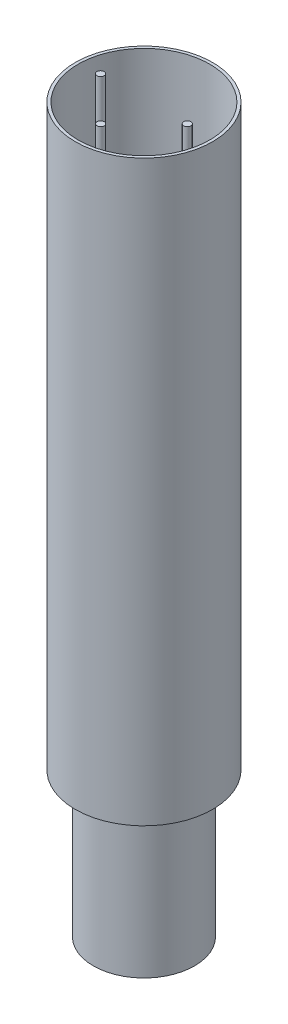
from build123d import *

# Parameters (mm, degrees)
SKETCH1_R             = 35
BOSS_EXTRUDE1_DEPTH   = 100
SKETCH2_R             = 47.5
BOSS_EXTRUDE2_DEPTH   = 400
SHELL1_T              = -2
SKETCH3_R             = 2.5
BOSS_EXTRUDE3_DEPTH   = 400
BOSS_EXTRUDE3_2_DEPTH = 400
BOSS_EXTRUDE3_3_DEPTH = 400


with BuildPart() as part:
    # Sketch1 → Boss-Extrude1 (new body)
    with BuildSketch(Plane(origin=(0, 0, 0), x_dir=(1, 0, 0), z_dir=(0, 1, 0))):
        with Locations(Location((0, 0, 0), (0, 0, 270))):
            Circle(SKETCH1_R)
    extrude(amount=BOSS_EXTRUDE1_DEPTH)

    # Sketch2 → Boss-Extrude2 (add)
    with BuildSketch(Plane(origin=(0, 100, 0), x_dir=(1, 0, 0), z_dir=(0, 1, 0))):
        with Locations(Location((0, 0, 0), (0, 0, 270))):
            Circle(SKETCH2_R)
    extrude(amount=BOSS_EXTRUDE2_DEPTH)

    # Shell1
    shell1_openings = [part.faces().sort_by_distance(p)[0] for p in [
        (0, 500, 0),
    ]]
    offset(amount=SHELL1_T, openings=shell1_openings, kind=Kind.INTERSECTION)


with BuildPart() as body_2:
    # Sketch3 → Boss-Extrude3 (new body)
    with BuildSketch(Plane(origin=(0, 102, 0), x_dir=(1, 0, 0), z_dir=(0, 1, 0))):
        with Locations(Location((0, -30, 0), (0, 0, 270))):
            Circle(SKETCH3_R)
    extrude(amount=BOSS_EXTRUDE3_DEPTH)


with BuildPart() as body_3:
    # Sketch3 → Boss-Extrude3 2 (new body)
    with BuildSketch(Plane(origin=(0, 102, 0), x_dir=(1, 0, 0), z_dir=(0, 1, 0))):
        with Locations(Location((-30, 0, 0), (0, 0, 270))):
            Circle(SKETCH3_R)
    extrude(amount=BOSS_EXTRUDE3_2_DEPTH)


with BuildPart() as body_4:
    # Sketch3 → Boss-Extrude3 3 (new body)
    with BuildSketch(Plane(origin=(0, 102, 0), x_dir=(1, 0, 0), z_dir=(0, 1, 0))):
        with Locations(Location((30, 0, 0), (0, 0, 270))):
            Circle(SKETCH3_R)
    extrude(amount=BOSS_EXTRUDE3_3_DEPTH)


solid = Compound([part.part, body_2.part, body_3.part, body_4.part])
